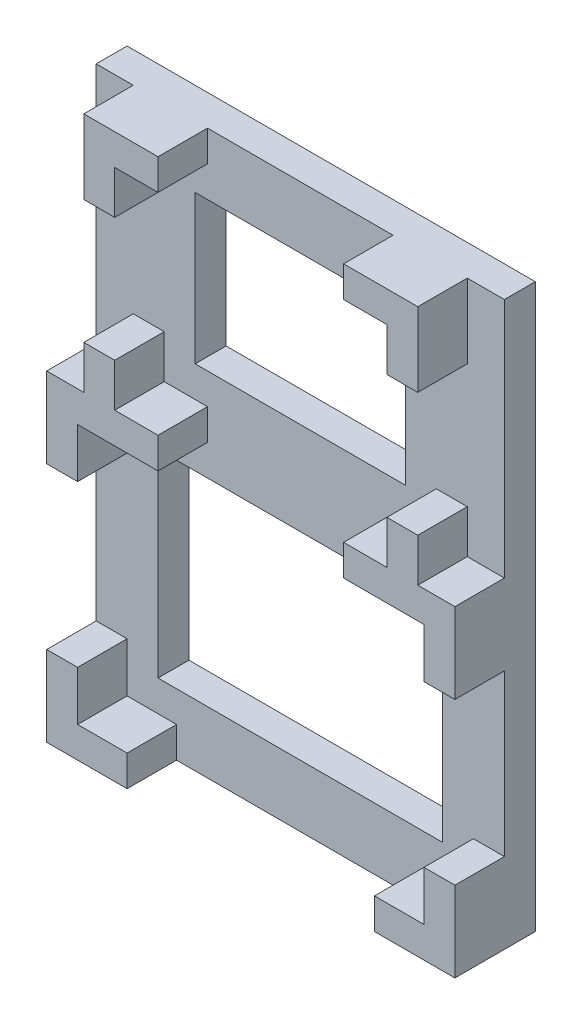
from build123d import *

# Parameters (mm, degrees)
SKETCH1_W             = 40
SKETCH1_H             = 5
BOSS_EXTRUDE1_DEPTH   = 5
SKETCH1_W_2           = 5
SKETCH1_H_2           = 26
BOSS_EXTRUDE1_2_DEPTH = 5
BOSS_EXTRUDE1_3_DEPTH = 5
SKETCH1_W_3           = 34
SKETCH1_H_3           = 24
BOSS_EXTRUDE1_4_DEPTH = 5
BOSS_EXTRUDE2_DEPTH   = 13
SKETCH2_W             = 46
SKETCH2_H             = 32
BOSS_EXTRUDE6_DEPTH   = 5


with BuildPart() as part:
    # Sketch1 → Boss-Extrude1 (new body)
    with BuildSketch(Plane.XY):
        with Locations((33, 2.5)):
            Rectangle(SKETCH1_W, SKETCH1_H)
    extrude(amount=BOSS_EXTRUDE1_DEPTH)



with BuildPart() as body_2:
    # Sketch1 → Boss-Extrude1 2 (new body)
    with BuildSketch(Plane.XY):
        with Locations((2.5, 26)):
            Rectangle(SKETCH1_W_2, SKETCH1_H_2)
    extrude(amount=BOSS_EXTRUDE1_2_DEPTH)


with BuildPart() as body_3:
    # Sketch1 → Boss-Extrude1 3 (new body)
    with BuildSketch(Plane.XY):
        with Locations((63.5, 26)):
            Rectangle(SKETCH1_W_2, SKETCH1_H_2)
    extrude(amount=BOSS_EXTRUDE1_3_DEPTH)


with BuildPart() as body_4:
    # Sketch1 → Boss-Extrude1 4 (new body)
    with BuildSketch(Plane.XY):
        Polygon((0, 91), (0, 52), (6, 52), (6, 59), (11, 59), (11, 52), (18, 52), (18, 47), (48, 47), (48, 52), (55, 52), (55, 59), (60, 59), (60, 52), (66, 52), (66, 91), (60, 91), (60, 79), (55, 79), (55, 86), (48, 86), (48, 91), (18, 91), (18, 86), (11, 86), (11, 79), (6, 79), (6, 91), align=None)
        with Locations((33, 69)):
            Rectangle(SKETCH1_W_3, SKETCH1_H_3, mode=Mode.SUBTRACT)
    extrude(amount=BOSS_EXTRUDE1_4_DEPTH)


with BuildPart() as part_1:
    add(part.part)

    add(body_2.part)  # Boss-Extrude2 merges body 2

    add(body_3.part)  # Boss-Extrude2 merges body 3

    add(body_4.part)  # Boss-Extrude2 merges body 4
    # Sketch1_3 → Boss-Extrude2 (add)
    with BuildSketch(Plane.XY):
        Polygon((0, 13), (0, 0), (13, 0), (13, 5), (5, 5), (5, 13), align=None)
        Polygon((53, 5), (53, 0), (66, 0), (66, 13), (61, 13), (61, 5), align=None)
        Polygon((0, 52), (0, 39), (5, 39), (5, 47), (18, 47), (18, 52), (11, 52), (11, 59), (6, 59), (6, 52), align=None)
        Polygon((61, 47), (61, 39), (66, 39), (66, 52), (60, 52), (60, 59), (55, 59), (55, 52), (48, 52), (48, 47), align=None)
        Polygon((18, 91), (6, 91), (6, 79), (11, 79), (11, 86), (18, 86), align=None)
        Polygon((60, 91), (48, 91), (48, 86), (55, 86), (55, 79), (60, 79), align=None)
    extrude(amount=BOSS_EXTRUDE2_DEPTH)

    # Sketch2 → Boss-Extrude6 (add)
    with BuildSketch(Plane.XY.offset(5)):
        Polygon((5, 10), (5, 5), (10, 5), (13, 5), (53, 5), (56, 5), (61, 5), (61, 10), (61, 42), (61, 47), (56, 47), (10, 47), (5, 47), (5, 42), align=None)
        with Locations((33, 26)):
            Rectangle(SKETCH2_W, SKETCH2_H, mode=Mode.SUBTRACT)
    extrude(amount=-BOSS_EXTRUDE6_DEPTH)


solid = part_1.part
